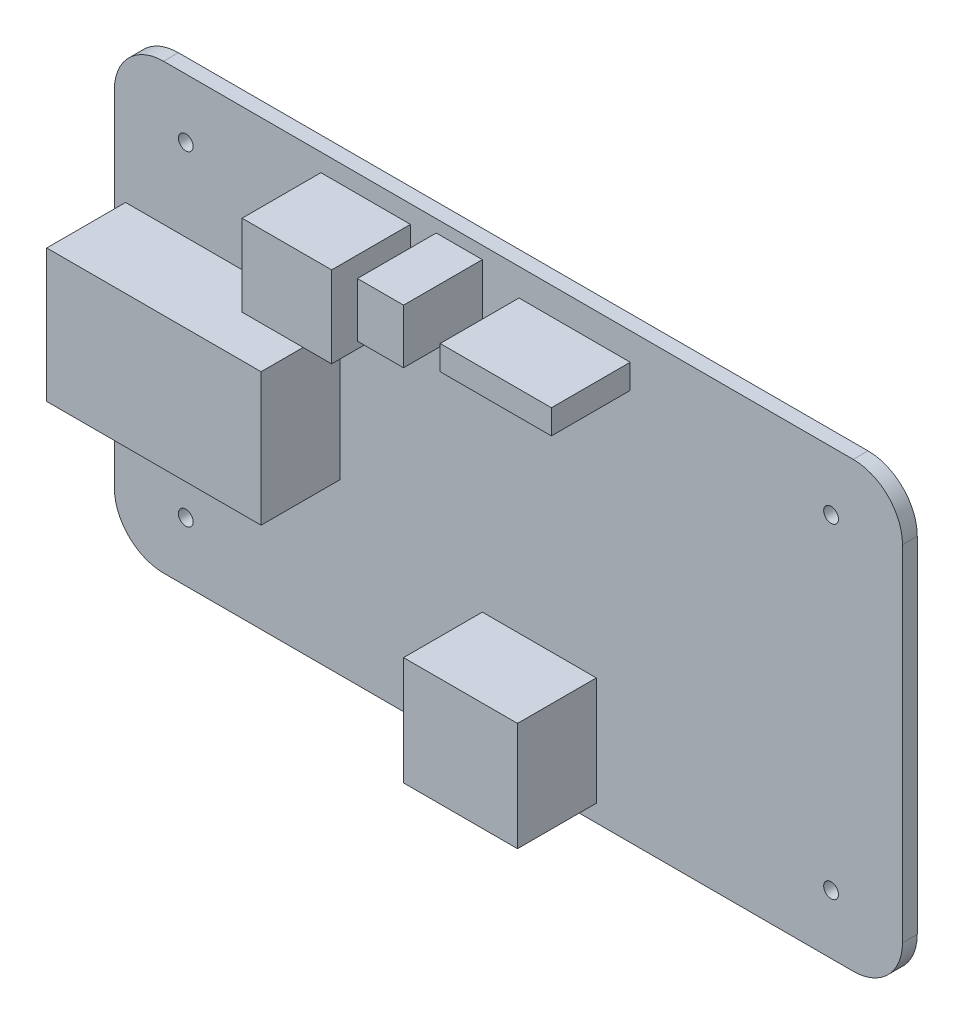
from build123d import *

# Parameters (mm, degrees)
SKETCH1_W           = 160
SKETCH1_H           = 90
BOSS_EXTRUDE1_DEPTH = 3
FILLET1_R           = 10
SKETCH2_R           = 1.5
CUT_EXTRUDE1_DEPTH  = 4
SKETCH3_W           = 43.515917568
SKETCH3_H           = 26.99088558
SKETCH3_W_2         = 23.135044783
SKETCH3_H_2         = 22.033375984
SKETCH3_W_3         = 18.177535187
SKETCH3_H_3         = 16.525031987
SKETCH3_W_4         = 9.364184793
SKETCH3_H_4         = 11.016687992
SKETCH3_W_5         = 22.584210384
SKETCH3_H_5         = 4.957509597
BOSS_EXTRUDE2_DEPTH = 16


with BuildPart() as part:
    # Sketch1 → Boss-Extrude1 (new body)
    with BuildSketch(Plane.XY):
        Rectangle(SKETCH1_W, SKETCH1_H)
    extrude(amount=BOSS_EXTRUDE1_DEPTH)

    # Fillet1
    fillet1_edges = [part.edges().sort_by_distance(p)[0] for p in [
        (80, -45, 1.5),
        (-80, -45, 1.5),
        (-80, 45, 1.5),
        (80, 45, 1.5),
    ]]
    fillet(fillet1_edges, radius=FILLET1_R)

    # Sketch2 → Cut-Extrude1 (cut, through all)
    with BuildSketch(Plane.XY.offset(3)):
        with Locations((-65.5, 33)):
            Circle(SKETCH2_R)
        with Locations((65.5, 33)):
            Circle(SKETCH2_R)
        with Locations((65.5, -33)):
            Circle(SKETCH2_R)
        with Locations((-65.5, -33)):
            Circle(SKETCH2_R)
    extrude(amount=-CUT_EXTRUDE1_DEPTH, mode=Mode.SUBTRACT)

    # Sketch3 → Boss-Extrude2 (add)
    with BuildSketch(Plane.XY.offset(3)):
        with Locations((-55.967549569, 2.815480553)):
            Rectangle(SKETCH3_W, SKETCH3_H)
        with Locations((6.276737585, -30.510000623)):
            Rectangle(SKETCH3_W_2, SKETCH3_H_2)
        with Locations((-28.976663989, 33.111372531)):
            Rectangle(SKETCH3_W_3, SKETCH3_H_3)
        with Locations((-9.972877203, 36.967213328)):
            Rectangle(SKETCH3_W_4, SKETCH3_H_4)
        with Locations((13.43758478, 36.967213328)):
            Rectangle(SKETCH3_W_5, SKETCH3_H_5)
    extrude(amount=BOSS_EXTRUDE2_DEPTH)


solid = part.part
